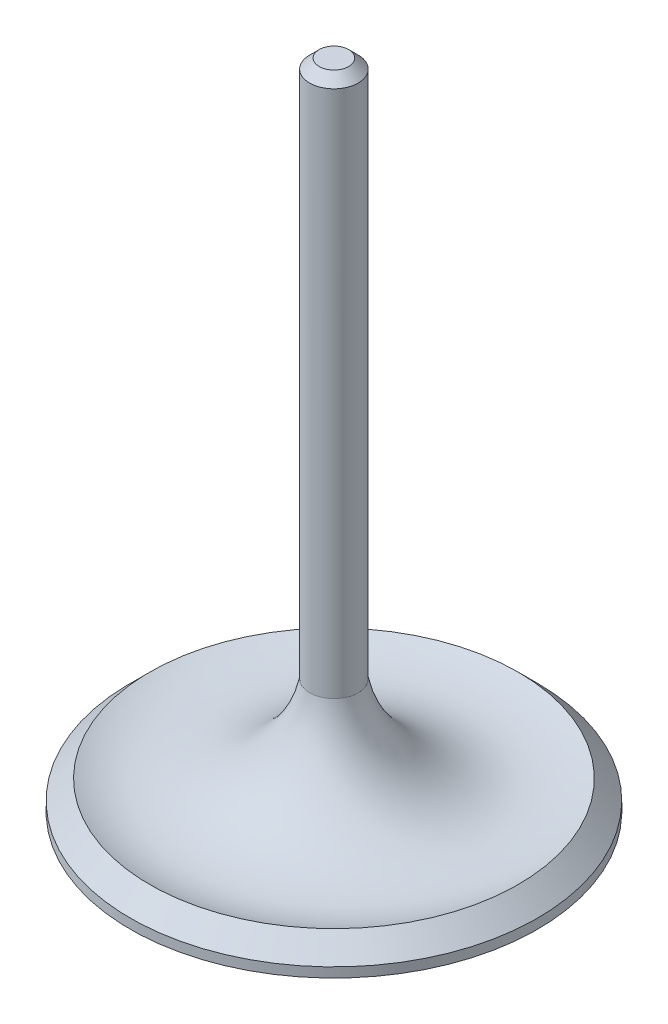
from build123d import *

# Parameters (mm, degrees)
CHAMFER1_SIZE = 1.25


with BuildPart() as part:
    # Sketch1 → Revolve1 (revolve)
    with BuildSketch(Plane(origin=(0, 0, 0), x_dir=(0, 0, -1), z_dir=(1, 0, 0))):
        with BuildLine():
            Line((0, 0), (0, 85.55))
            Line((0, 85.55), (3.18, 85.55))
            Line((3.18, 85.55), (3.18, 15.100044805))
            ThreePointArc((3.18, 15.100044805), (10.945145292, 4.426569715), (24.13, 3.81))
            Line((24.13, 3.81), (26.67, 1.27))
            Line((26.67, 1.27), (26.67, 0))
            Line((26.67, 0), (0, 0))
        make_face()
    revolve(axis=Axis((0, 0, 0), (0, 1, 0)))

    # Chamfer1
    chamfer1_edges = [part.edges().sort_by_distance(p)[0] for p in [
        (0, 85.55, 3.18),
    ]]
    chamfer(chamfer1_edges, length=CHAMFER1_SIZE)


solid = part.part
